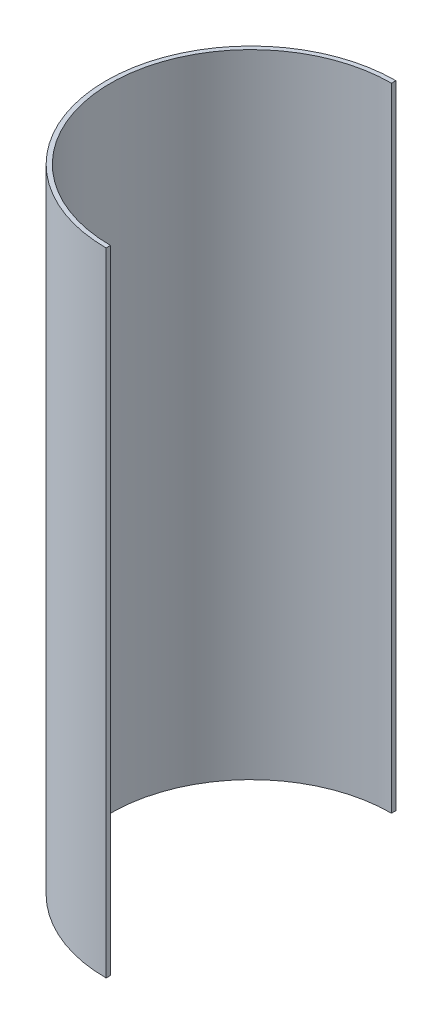
from build123d import *

# Parameters (mm, degrees)
BOSS_EXTRUDE1_DEPTH = 457.2


with BuildPart() as part:
    # Sketch1 → Boss-Extrude1 (new body)
    with BuildSketch(Plane(origin=(0, 0, 0), x_dir=(1, 0, 0), z_dir=(0, 1, 0))):
        with BuildLine():
            Line((0, 104.775), (0, 101.6))
            ThreePointArc((0, 101.6), (-101.6, 0), (0, -101.6))
            Line((0, -101.6), (0, -104.775))
            ThreePointArc((0, -104.775), (-104.775, 0), (0, 104.775))
        make_face()
    extrude(amount=BOSS_EXTRUDE1_DEPTH)


solid = part.part
